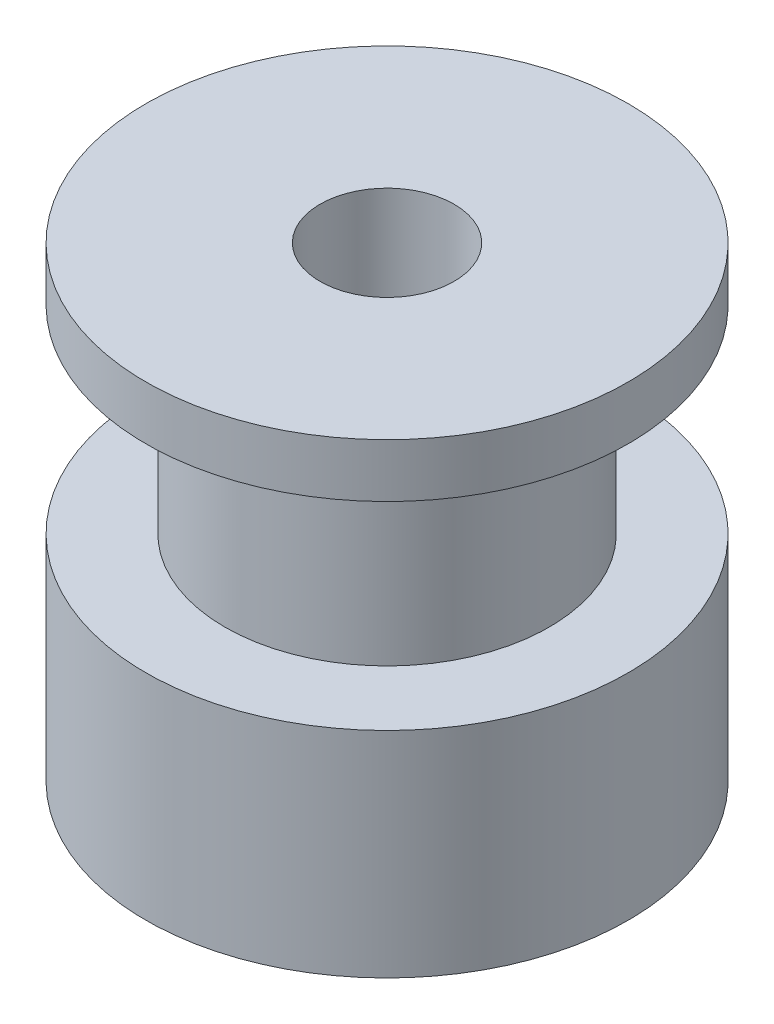
from build123d import *


with BuildPart() as part:
    # Эскиз1 → Повернуть1 (revolve)
    with BuildSketch(Plane.XY):
        Polygon((-2.5, 17.4), (-9, 17.4), (-9, 15.4), (-6.05, 15.4), (-6.05, 8), (-9, 8), (-9, 0), (-2.5, 0), align=None)
    revolve(axis=Axis((0, 0, 0), (0, 1, 0)))


solid = part.part
